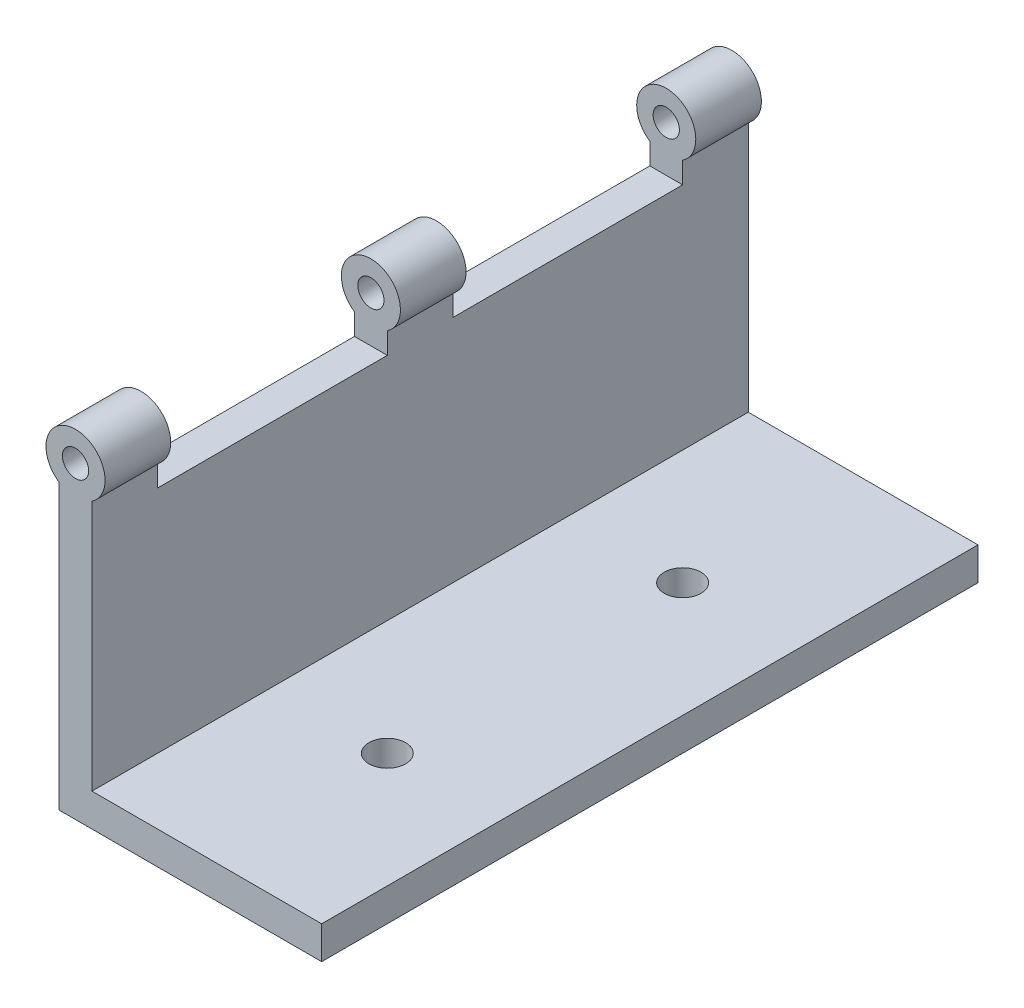
from build123d import *

# Parameters (mm, degrees)
BOSS_EXTRUDE1_DEPTH = 50
SKETCH7_R           = 4.5
SKETCH7_R_2         = 2
SKETCH7_W           = 5
SKETCH7_H           = 3.258342613
BOSS_EXTRUDE4_DEPTH = 5
SKETCH2_R           = 4.5
SKETCH2_R_2         = 2
SKETCH2_W           = 5
SKETCH2_H           = 3.258342613
BOSS_EXTRUDE3_DEPTH = 10
SKETCH12_R          = 2.8
CUT_EXTRUDE1_DEPTH  = 6


with BuildPart() as part:
    # Sketch1 → Boss-Extrude1 (new body, symmetric)
    with BuildSketch(Plane.XY):
        Polygon((0, 0), (0, 40), (5, 40), (5, 5), (40, 5), (40, 0), align=None)
    extrude(amount=BOSS_EXTRUDE1_DEPTH, both=True)

    # Sketch7 → Boss-Extrude4 (add, symmetric)
    with BuildSketch(Plane.XY):
        with Locations((2.5, 47)):
            Circle(SKETCH7_R)
        with Locations((2.5, 47)):
            Circle(SKETCH7_R_2, mode=Mode.SUBTRACT)
        with Locations((2.5, 41.629171306)):
            Rectangle(SKETCH7_W, SKETCH7_H)
    extrude(amount=BOSS_EXTRUDE4_DEPTH, both=True)

    # Sketch2 → Boss-Extrude3 (add)
    with BuildSketch(Plane.XY.offset(50)):
        with Locations((2.5, 47)):
            Circle(SKETCH2_R)
        with Locations((2.5, 47)):
            Circle(SKETCH2_R_2, mode=Mode.SUBTRACT)
        with Locations((2.5, 41.629171306)):
            Rectangle(SKETCH2_W, SKETCH2_H)
    boss_extrude3 = extrude(amount=-BOSS_EXTRUDE3_DEPTH)

    # Mirror1: Boss-Extrude3 across plane
    add(boss_extrude3.mirror(Plane.XY))

    # Sketch12 → Cut-Extrude1 (cut, through all)
    with BuildSketch(Plane(origin=(0, 5, 0), x_dir=(1, 0, 0), z_dir=(0, 1, 0))):
        with Locations((22.5, 22.5)):
            Circle(SKETCH12_R)
        with Locations((22.5, -22.5)):
            Circle(SKETCH12_R)
    extrude(amount=-CUT_EXTRUDE1_DEPTH, mode=Mode.SUBTRACT)


solid = part.part
